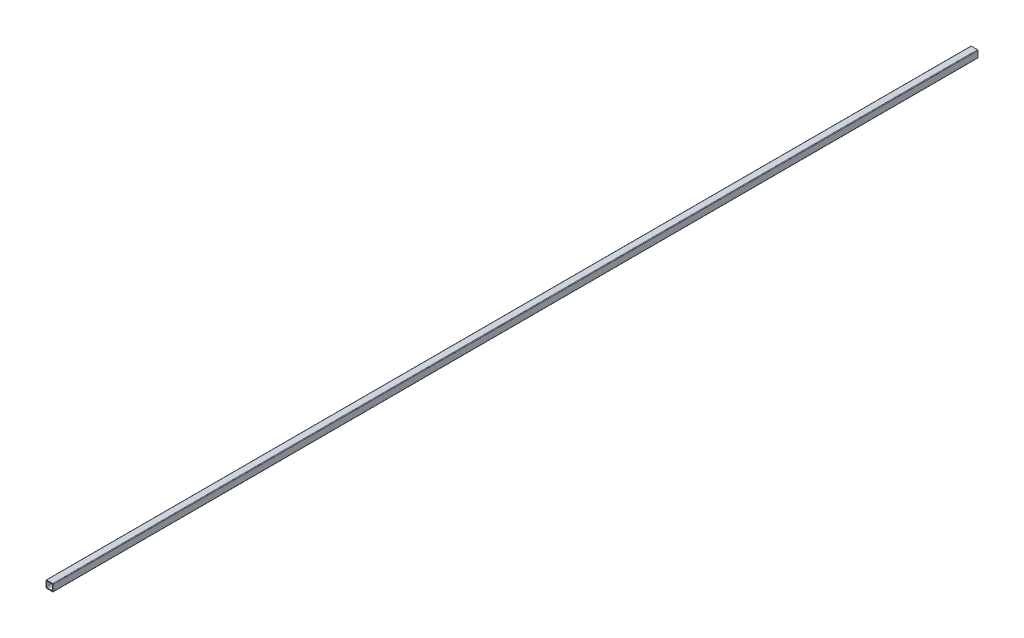
from build123d import *

# Parameters (mm, degrees)
BOSS_EXTRUDE1_DEPTH = 2438.4
CUT_EXTRUDE1_DEPTH  = 2439.4


with BuildPart() as part:
    # Sketch1 → Boss-Extrude1 (new body)
    with BuildSketch(Plane.XY):
        with BuildLine():
            Line((1.524, 0), (17.526, 0))
            ThreePointArc((17.526, 0), (18.603630735, 0.446369265), (19.05, 1.524))
            Line((19.05, 1.524), (19.05, 17.526))
            ThreePointArc((19.05, 17.526), (18.603630735, 18.603630735), (17.526, 19.05))
            Line((17.526, 19.05), (1.524, 19.05))
            ThreePointArc((1.524, 19.05), (0.446369265, 18.603630735), (0, 17.526))
            Line((0, 17.526), (0, 1.524))
            ThreePointArc((0, 1.524), (0.446369265, 0.446369265), (1.524, 0))
        make_face()
    extrude(amount=-BOSS_EXTRUDE1_DEPTH)

    # Sketch2 → Cut-Extrude1 (cut, through all)
    with BuildSketch(Plane.XY):
        with BuildLine():
            Line((5.08, 17.145), (13.97, 17.145))
            ThreePointArc((13.97, 17.145), (16.21506403, 16.21506403), (17.145, 13.97))
            Line((17.145, 13.97), (17.145, 5.08))
            ThreePointArc((17.145, 5.08), (16.21506403, 2.83493597), (13.97, 1.905))
            Line((13.97, 1.905), (5.08, 1.905))
            ThreePointArc((5.08, 1.905), (2.83493597, 2.83493597), (1.905, 5.08))
            Line((1.905, 5.08), (1.905, 13.97))
            ThreePointArc((1.905, 13.97), (2.83493597, 16.21506403), (5.08, 17.145))
        make_face()
    extrude(amount=-CUT_EXTRUDE1_DEPTH, mode=Mode.SUBTRACT)


solid = part.part
